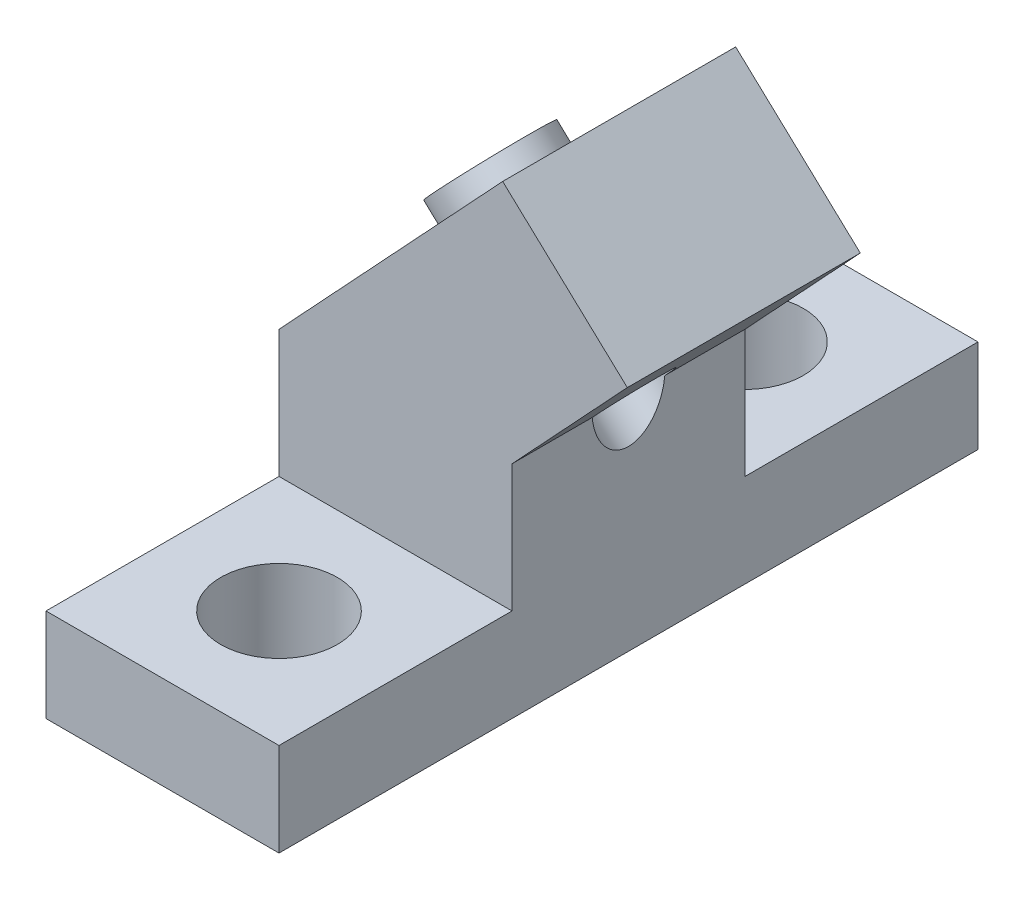
from build123d import *

# Parameters (mm, degrees)
BOSS_EXTRUDE3_DEPTH = 12.7
SKETCH8_R           = 2
CUT_EXTRUDE5_DEPTH  = 12.7
CUT_EXTRUDE7_DEPTH  = 12.7
SKETCH10_W          = 12.7
SKETCH10_H          = 5.08
BOSS_EXTRUDE4_DEPTH = 12.7
SKETCH11_R          = 3.175
CUT_EXTRUDE8_DEPTH  = 12.7
SKETCH13_R          = 3
SKETCH13_R_2        = 2
BOSS_EXTRUDE5_DEPTH = 1.27


with BuildPart() as part:
    # Sketch7 → Boss-Extrude3 (new body)
    with BuildSketch(Plane.XY):
        Polygon((0, 12.027702426), (12.192, 25.102021739), (24.892, 25.102021739), (12.7, 12.027702426), (12.7, 0), (0, 0), align=None)
    extrude(amount=BOSS_EXTRUDE3_DEPTH)

    # Sketch8 → Cut-Extrude5 (cut)
    with BuildSketch(Plane(origin=(-5.999201774, 5.594346159, 0), x_dir=(0, 0, 1), z_dir=(-0.731353702, 0.68199836, 0))):
        with Locations((6.35, 17.734942607)):
            Circle(SKETCH8_R)
    extrude(amount=-CUT_EXTRUDE5_DEPTH, mode=Mode.SUBTRACT)

    # Sketch9 → Cut-Extrude7 (cut)
    with BuildSketch(Plane.XY.offset(12.7)):
        Polygon((12.192, 25.102021739), (18.984953608, 18.76749002), (24.892, 25.102021739), align=None)
    extrude(amount=-CUT_EXTRUDE7_DEPTH, mode=Mode.SUBTRACT)

    # Sketch10 → Boss-Extrude4 (add)
    with BuildSketch(Plane.XY.offset(12.7)):
        with Locations((6.35, 2.54)):
            Rectangle(SKETCH10_W, SKETCH10_H)
    boss_extrude4 = extrude(amount=BOSS_EXTRUDE4_DEPTH)

    # Sketch11 → Cut-Extrude8 (cut)
    with BuildSketch(Plane(origin=(0, 5.08, 0), x_dir=(1, 0, 0), z_dir=(0, 1, 0))):
        with Locations((6.35, -19.05)):
            Circle(SKETCH11_R)
    cut_extrude8 = extrude(amount=-CUT_EXTRUDE8_DEPTH, mode=Mode.SUBTRACT)

    # Mirror2: Boss-Extrude4, Cut-Extrude8 across plane
    add(boss_extrude4.mirror(Plane.XY.offset(6.35)))
    add(cut_extrude8.mirror(Plane.XY.offset(6.35)), mode=Mode.SUBTRACT)

    # Sketch13 → Boss-Extrude5 (add)
    with BuildSketch(Plane(origin=(-5.999201774, 5.594346159, 0), x_dir=(0, 0, 1), z_dir=(-0.731353702, 0.68199836, 0))):
        with Locations((6.35, 17.734942607)):
            Circle(SKETCH13_R)
        with Locations((6.35, 17.734942607)):
            Circle(SKETCH13_R_2, mode=Mode.SUBTRACT)
    extrude(amount=BOSS_EXTRUDE5_DEPTH)


solid = part.part
